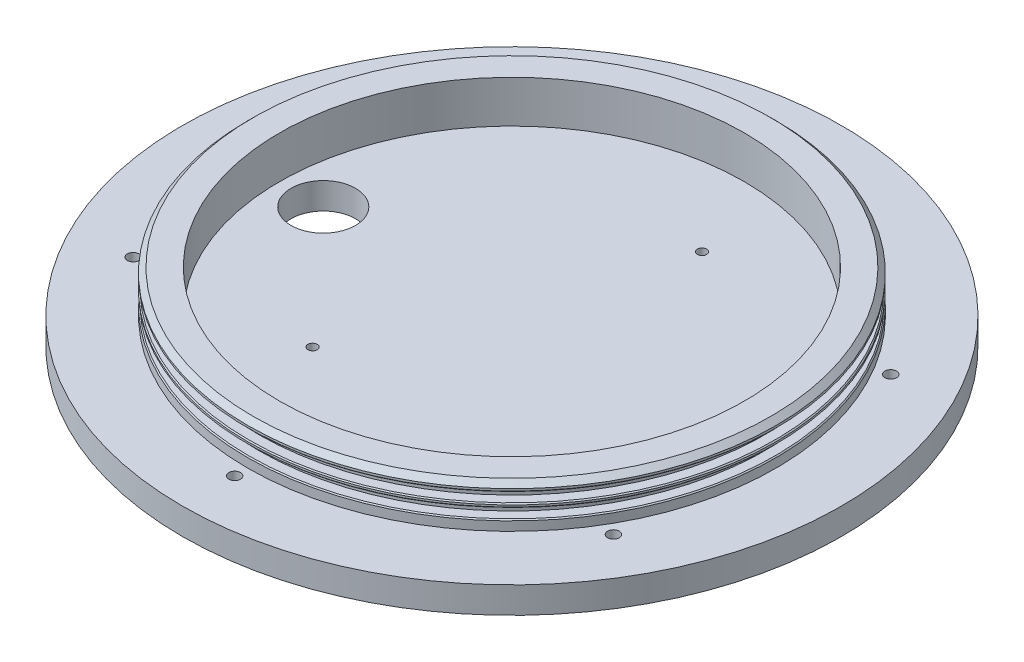
from build123d import *

# Parameters (mm, degrees)
SKETCH1_R                                      = 79.248
EXTRUDE1_DEPTH                                 = 3.175
EXTRUDE1_DEPTH_BACK                            = 3.175
SKETCH2_R                                      = 63.5
EXTRUDE2_DEPTH                                 = 10.16
SKETCH4_W                                      = 2.54
SKETCH4_H                                      = 2.3622
SKETCH5_R                                      = 55.88
CUT_EXTRUDE1_DEPTH                             = 10.16
CHAMFER1_SIZE                                  = 1.27
CHAMFER2_SIZE                                  = 0.254
CBORE_FOR_3_SOCKET_HEAD_CAP_SCREW1_D           = 2.794
CBORE_FOR_3_SOCKET_HEAD_CAP_SCREW1_CBORE_D     = 5.15874
CBORE_FOR_3_SOCKET_HEAD_CAP_SCREW1_CBORE_DEPTH = 2.5146
CIRPATTERN1_COUNT                              = 6
F_4_40_TAPPED_HOLE1_D                          = 2.2606
F_4_40_TAPPED_HOLE1_DEPTH                      = 5.08
F_4_40_TAPPED_HOLE1_TIP                        = 0.679152758
M14_CLEARANCE_HOLE1_D                          = 15.5
M14_CLEARANCE_HOLE1_DEPTH                      = 330.2
M14_CLEARANCE_HOLE1_TIP                        = 4.656669797
F_6_32_TAPPED_HOLE1_D                          = 2.7051
F_6_32_TAPPED_HOLE1_DEPTH                      = 4.318
F_6_32_TAPPED_HOLE1_CBORE_D                    = 3.5052
F_6_32_TAPPED_HOLE1_CBORE_DEPTH                = 3.556
F_6_32_TAPPED_HOLE1_TIP                        = 0.81269403
SKETCH21_R                                     = 3.175
SKETCH21_R_2                                   = 1.7526
BOSS_EXTRUDE1_DEPTH                            = 25.4


with BuildPart() as part:
    # Sketch1 → Extrude1 (new body, two sides)
    with BuildSketch(Plane(origin=(0, 0, 0), x_dir=(1, 0, 0), z_dir=(0, 1, 0))) as extrude1_sk:
        Circle(SKETCH1_R)
    extrude(amount=EXTRUDE1_DEPTH)
    extrude(extrude1_sk.sketch, amount=-EXTRUDE1_DEPTH_BACK)

    # Sketch2 → Extrude2 (add)
    with BuildSketch(Plane(origin=(0, 3.175, 0), x_dir=(-1, 0, 0), z_dir=(0, 1, 0))):
        Circle(SKETCH2_R)
    extrude(amount=EXTRUDE2_DEPTH)

    # Sketch4 → Cut-Revolve7 (revolve, cut)
    with BuildSketch(Plane(origin=(0, 0, 0), x_dir=(0, 0, -1), z_dir=(1, 0, 0))):
        with Locations((-62.23, 10.122310801)):
            Rectangle(SKETCH4_W, SKETCH4_H)
        with Locations((-62.23, 6.799968424)):
            Rectangle(SKETCH4_W, SKETCH4_H)
    revolve(axis=Axis((0, -3.175, 0), (0, 1, 0)), mode=Mode.SUBTRACT)

    # Sketch5 → Cut-Extrude1 (cut)
    with BuildSketch(Plane(origin=(0, 13.335, 0), x_dir=(-1, 0, 0), z_dir=(0, 1, 0))):
        Circle(SKETCH5_R)
    extrude(amount=-CUT_EXTRUDE1_DEPTH, mode=Mode.SUBTRACT)

    # Chamfer1
    chamfer1_edges = [part.edges().sort_by_distance(p)[0] for p in [
        (63.5, 13.335, 0),
    ]]
    chamfer(chamfer1_edges, length=CHAMFER1_SIZE)

    # Chamfer2
    chamfer2_edges = [part.edges().sort_by_distance(p)[0] for p in [
        (63.5, 11.303410801, 0),
        (63.5, 8.941210801, 0),
        (63.5, 7.981068424, 0),
        (63.5, 5.618868424, 0),
    ]]
    chamfer(chamfer2_edges, length=CHAMFER2_SIZE)

    # CBORE for _3 Socket Head Cap Screw1 (through all)
    with Locations(Plane(origin=(0, -3.175, 66.675), x_dir=(0, 0, -1), z_dir=(0, -1, 0))):
        with Locations((0, 0)):
            cbore_for_3_socket_head_cap_screw1 = CounterBoreHole(CBORE_FOR_3_SOCKET_HEAD_CAP_SCREW1_D / 2, CBORE_FOR_3_SOCKET_HEAD_CAP_SCREW1_CBORE_D / 2, CBORE_FOR_3_SOCKET_HEAD_CAP_SCREW1_CBORE_DEPTH)

    # CirPattern1: CBORE for _3 Socket Head Cap Screw1 ×6 about axis
    cirpattern1_axis = Axis((0, 0, 0), (0, 1, 0))
    for i in range(1, CIRPATTERN1_COUNT):
        add(cbore_for_3_socket_head_cap_screw1.rotate(cirpattern1_axis, i * 360 / CIRPATTERN1_COUNT), mode=Mode.SUBTRACT)

    # 4-40 Tapped Hole1
    with Locations(Plane(origin=(9.525, 3.175, -36.195), x_dir=(0, 0, 1), z_dir=(0, 1, 0))):
        with Locations((0, 0), (66.675, -26.9875)):
            Hole(F_4_40_TAPPED_HOLE1_D / 2, depth=F_4_40_TAPPED_HOLE1_DEPTH)
            with Locations((0, 0, -(F_4_40_TAPPED_HOLE1_DEPTH + F_4_40_TAPPED_HOLE1_TIP / 2))):  # 118° drill point
                Cone(0, F_4_40_TAPPED_HOLE1_D / 2, F_4_40_TAPPED_HOLE1_TIP, mode=Mode.SUBTRACT)

    # M14 Clearance Hole1
    with Locations(Plane(origin=(-45.367887501, 3.175, 0), x_dir=(0, 0, 1), z_dir=(0, 1, 0))):
        with Locations((0, 0)):
            Hole(M14_CLEARANCE_HOLE1_D / 2, depth=M14_CLEARANCE_HOLE1_DEPTH)
            with Locations((0, 0, -(M14_CLEARANCE_HOLE1_DEPTH + M14_CLEARANCE_HOLE1_TIP / 2))):  # 118° drill point
                Cone(0, M14_CLEARANCE_HOLE1_D / 2, M14_CLEARANCE_HOLE1_TIP, mode=Mode.SUBTRACT)

    # 6-32 Tapped Hole1
    with Locations(Plane(origin=(-19.05, -3.175, 20.574), x_dir=(0, 0, -1), z_dir=(0, -1, 0))):
        with Locations((0, 0), (0, 38.1), (41.148, 38.1), (41.148, 0)):
            CounterBoreHole(F_6_32_TAPPED_HOLE1_D / 2, F_6_32_TAPPED_HOLE1_CBORE_D / 2, F_6_32_TAPPED_HOLE1_CBORE_DEPTH, depth=F_6_32_TAPPED_HOLE1_DEPTH)
            with Locations((0, 0, -(F_6_32_TAPPED_HOLE1_DEPTH + F_6_32_TAPPED_HOLE1_TIP / 2))):  # 118° drill point
                Cone(0, F_6_32_TAPPED_HOLE1_D / 2, F_6_32_TAPPED_HOLE1_TIP, mode=Mode.SUBTRACT)

    # Sketch21 → Boss-Extrude1 (add)
    with BuildSketch(Plane.XZ.offset(3.175)):
        with Locations((19.05, -20.574)):
            Circle(SKETCH21_R)
        with Locations((19.05, -20.574)):
            Circle(SKETCH21_R_2, mode=Mode.SUBTRACT)
        with Locations((-19.05, -20.574)):
            Circle(SKETCH21_R)
        with Locations((-19.05, -20.574)):
            Circle(SKETCH21_R_2, mode=Mode.SUBTRACT)
        with Locations((-19.05, 20.574)):
            Circle(SKETCH21_R)
        with Locations((-19.05, 20.574)):
            Circle(SKETCH21_R_2, mode=Mode.SUBTRACT)
        with Locations((19.05, 20.574)):
            Circle(SKETCH21_R)
        with Locations((19.05, 20.574)):
            Circle(SKETCH21_R_2, mode=Mode.SUBTRACT)
    extrude(amount=BOSS_EXTRUDE1_DEPTH)


solid = part.part
